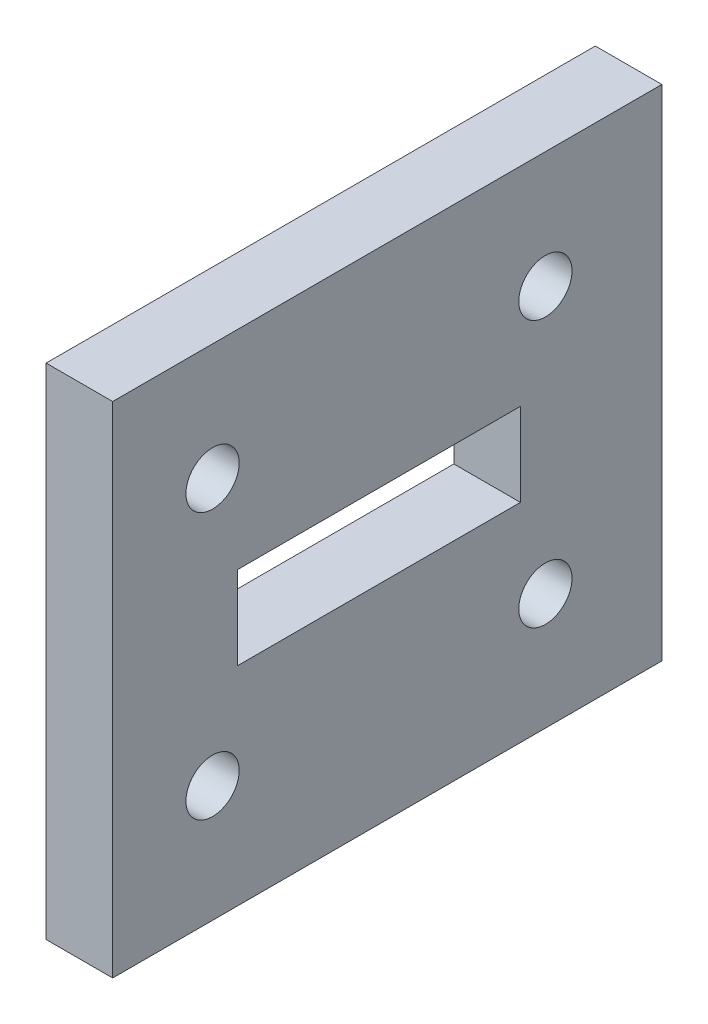
from build123d import *

# Parameters (mm, degrees)
SKETCH_1_W         = 33
SKETCH_1_H         = 30
SKETCH_1_R         = 1.6
EXTRUDE_1_DEPTH    = 4
SKETCH2_W          = 17
SKETCH2_H          = 5
CUT_EXTRUDE2_DEPTH = 5


with BuildPart() as part:
    # Эскиз1 → Бобышка-Вытянуть1 (new body)
    with BuildSketch(Plane(origin=(15.473923778, 0, 0), x_dir=(0, 0, -1), z_dir=(1, 0, 0))):
        with Locations((3.263696673, 23.493617857)):
            Rectangle(SKETCH_1_W, SKETCH_1_H)
        with Locations((-7.236303327, 31.493617857)):
            Circle(SKETCH_1_R, mode=Mode.SUBTRACT)
        with Locations((12.763696673, 31.493617857)):
            Circle(SKETCH_1_R, mode=Mode.SUBTRACT)
        with Locations((-7.236303327, 15.493617857)):
            Circle(SKETCH_1_R, mode=Mode.SUBTRACT)
        with Locations((12.763696673, 15.493617857)):
            Circle(SKETCH_1_R, mode=Mode.SUBTRACT)
    extrude(amount=EXTRUDE_1_DEPTH)

    # Sketch2 → Cut-Extrude2 (cut, through all)
    with BuildSketch(Plane.ZY.offset(-15.473923778)):
        with Locations((-2.763696673, 23.493617857)):
            Rectangle(SKETCH2_W, SKETCH2_H)
    extrude(amount=-CUT_EXTRUDE2_DEPTH, mode=Mode.SUBTRACT)


solid = part.part
